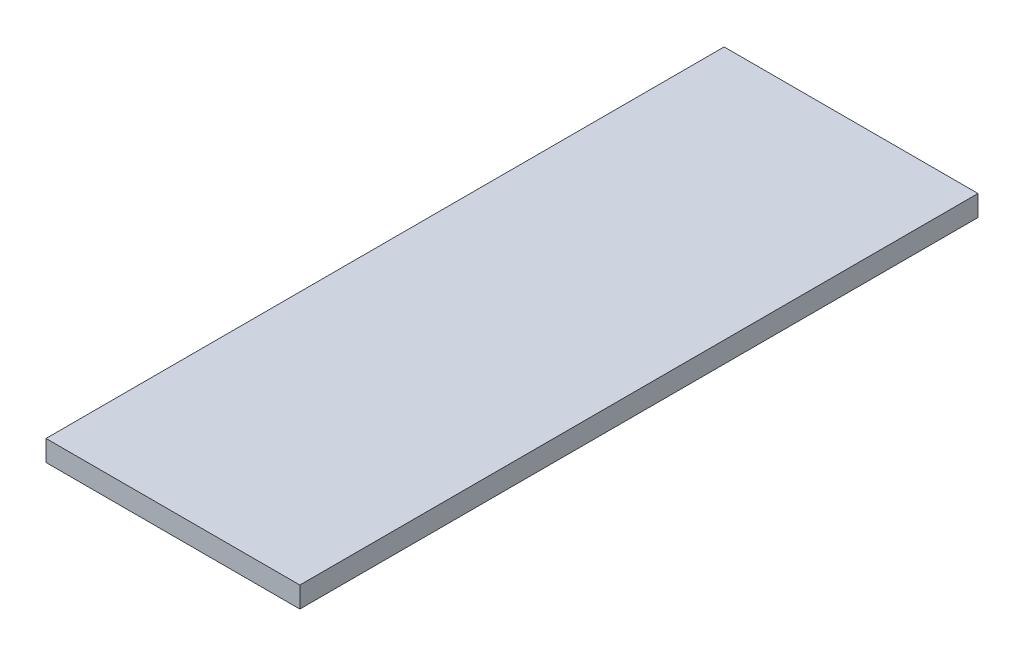
from build123d import *

# Parameters (mm, degrees)
SKETCH1_W           = 38.65
SKETCH1_H           = 128.65
BOSS_EXTRUDE1_DEPTH = 3.175
SKETCH5_W           = 38.65
SKETCH5_H           = 25.4
CUT_EXTRUDE3_DEPTH  = 4.175


with BuildPart() as part:
    # Sketch1 → Boss-Extrude1 (new body)
    with BuildSketch(Plane(origin=(0, 0, 0), x_dir=(1, 0, 0), z_dir=(0, 1, 0))):
        Rectangle(SKETCH1_W, SKETCH1_H)
    extrude(amount=BOSS_EXTRUDE1_DEPTH)

    # Sketch5 → Cut-Extrude3 (cut, through all)
    with BuildSketch(Plane(origin=(0, 3.175, 0), x_dir=(1, 0, 0), z_dir=(0, 1, 0))):
        with Locations((0, 51.625)):
            Rectangle(SKETCH5_W, SKETCH5_H)
    extrude(amount=-CUT_EXTRUDE3_DEPTH, mode=Mode.SUBTRACT)


solid = part.part
